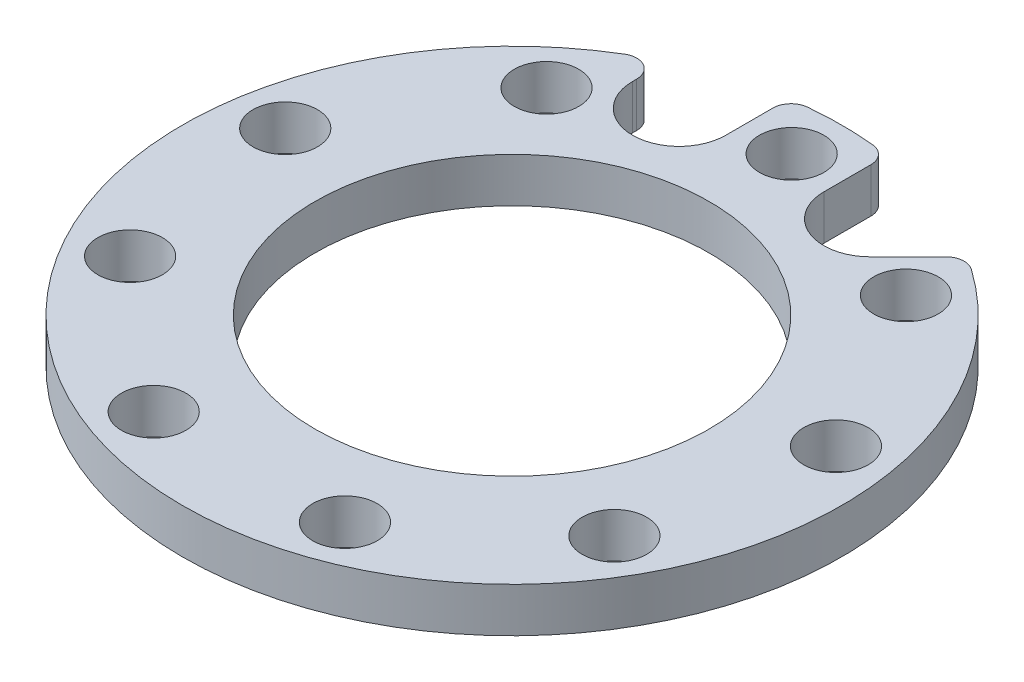
from build123d import *

# Parameters (mm, degrees)
SKETCH1_R            = 45.974
SKETCH1_R_2          = 27.4955
SKETCH1_R_3          = 6.5
BOSS_EXTRUDE1_DEPTH  = 6.21400078
M8_CLEARANCE_HOLE1_D = 9
CIRPATTERN1_COUNT    = 9
CUT_EXTRUDE1_DEPTH   = 7.21400078
FILLET1_R            = 2.54


with BuildPart() as part:
    # Sketch1 → Boss-Extrude1 (new body)
    with BuildSketch(Plane(origin=(0, 0, 0), x_dir=(1, 0, 0), z_dir=(0, 1, 0))):
        Circle(SKETCH1_R)
        Circle(SKETCH1_R_2, mode=Mode.SUBTRACT)
        with Locations((-13.33878559, 36.648012211)):
            Circle(SKETCH1_R_3, mode=Mode.SUBTRACT)
        with Locations((13.33878559, 36.648012211)):
            Circle(SKETCH1_R_3, mode=Mode.SUBTRACT)
    extrude(amount=BOSS_EXTRUDE1_DEPTH)

    # M8 Clearance Hole1 (through all)
    with Locations(Plane(origin=(0, 6.21400078, 0), x_dir=(1, 0, 0), z_dir=(0, 1, 0))):
        with Locations((0, 39)):
            m8_clearance_hole1 = Hole(M8_CLEARANCE_HOLE1_D / 2)

    # CirPattern1: M8 Clearance Hole1 ×9 about axis
    cirpattern1_axis = Axis((0, 0, 0), (0, 1, 0))
    for i in range(1, CIRPATTERN1_COUNT):
        add(m8_clearance_hole1.rotate(cirpattern1_axis, i * 360 / CIRPATTERN1_COUNT), mode=Mode.SUBTRACT)

    # Sketch6 → Cut-Extrude1 (cut, through all)
    with BuildSketch(Plane(origin=(0, 6.21400078, 0), x_dir=(1, 0, 0), z_dir=(0, 1, 0))):
        with BuildLine():
            Line((17.934979667, 32.051818133), (24.674577095, 38.79141556))
            ThreePointArc((24.674577095, 38.79141556), (16.105864692, 43.06053644), (6.83878559, 45.462508594))
            Line((6.83878559, 45.462508594), (6.83878559, 36.648012211))
            ThreePointArc((6.83878559, 36.648012211), (15.8262279, 42.653229172), (17.934979667, 32.051818133))
        make_face()
        with BuildLine():
            Line((-6.83878559, 36.648012211), (-6.83878559, 45.462508594))
            ThreePointArc((-6.83878559, 45.462508594), (-13.487094864, 43.951188245), (-19.83878559, 41.473259606))
            Line((-19.83878559, 41.473259606), (-19.83878559, 36.648012211))
            ThreePointArc((-19.83878559, 36.648012211), (-13.33878559, 43.148012211), (-6.83878559, 36.648012211))
        make_face()
    extrude(amount=-CUT_EXTRUDE1_DEPTH, mode=Mode.SUBTRACT)

    # Fillet1
    fillet1_edges = [part.edges().sort_by_distance(p)[0] for p in [
        (6.83878559, 3.10700039, -45.462508594),
        (24.674577095, 3.10700039, -38.79141556),
        (-19.83878559, 3.10700039, -41.473259606),
        (-6.83878559, 3.10700039, -45.462508594),
    ]]
    fillet(fillet1_edges, radius=FILLET1_R)


solid = part.part
